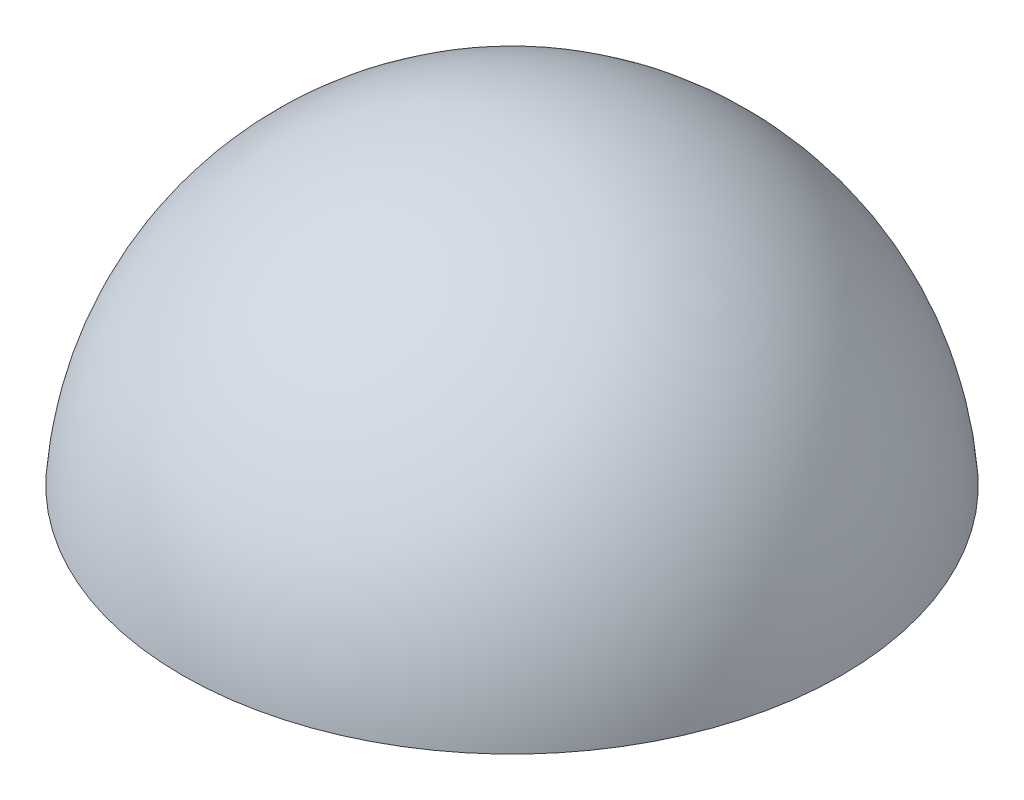
from build123d import *


with BuildPart() as part:
    # Sketch1 one side → Revolve1 (revolve)
    with BuildSketch(Plane.XY):
        with BuildLine():
            ThreePointArc((0, 15.615824185), (-11.481368286, 11.110822333), (-16.835477596, 0))
            Line((-16.835477596, 0), (0, 0))
            Line((0, 0), (0, 15.615824185))
        make_face()
    revolve(axis=Axis((0, 0, 0), (0, 1, 0)))


solid = part.part
